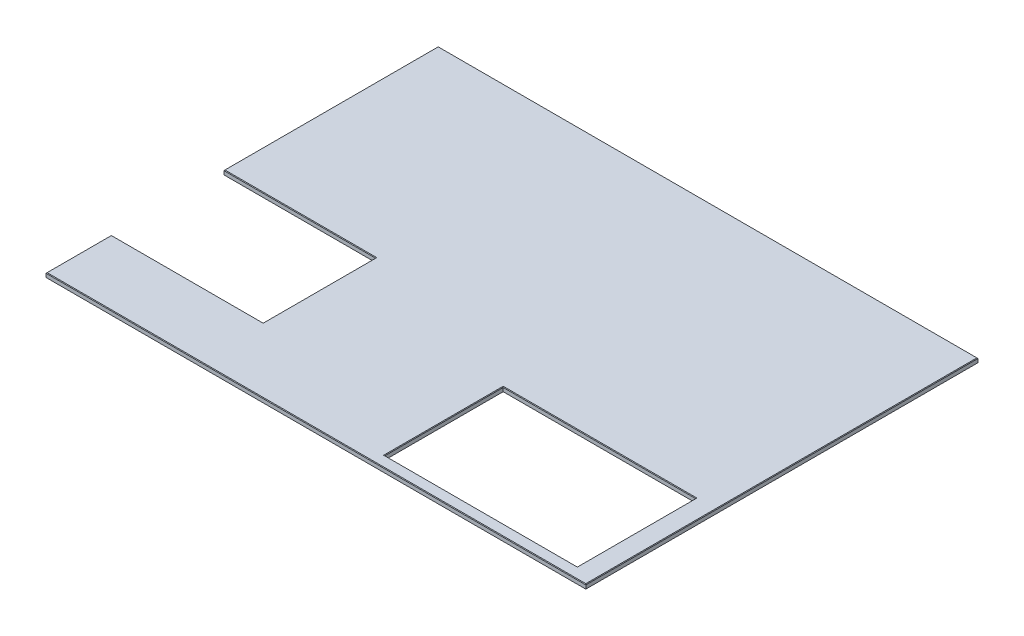
from build123d import *

# Parameters (mm, degrees)
SKETCH1_W           = 869.95
SKETCH1_H           = 534.924
BOSS_EXTRUDE1_DEPTH = 19.05
CHAMFER1_SIZE       = 2.54


with BuildPart() as part:
    # Sketch1 → Boss-Extrude1 (new body)
    with BuildSketch(Plane(origin=(0, 0, 0), x_dir=(1, 0, 0), z_dir=(0, 1, 0))):
        Polygon((2438.4, 0), (2438.4, 1771.65), (0, 1771.65), (0, 803.275), (685.8, 803.275), (685.8, 295.275), (0, 295.275), (0, 0), align=None)
        with Locations((1914.4615, 318.262)):
            Rectangle(SKETCH1_W, SKETCH1_H, mode=Mode.SUBTRACT)
    extrude(amount=-BOSS_EXTRUDE1_DEPTH)

    # Chamfer1
    chamfer1_edges = [part.edges().sort_by_distance(p)[0] for p in [
        (0, 0, -1287.4625),
        (1219.2, 0, -1771.65),
        (2438.4, 0, -885.825),
        (1219.2, 0, 0),
        (1914.4615, 0, -585.724),
        (1479.4865, 0, -318.262),
        (1914.4615, 0, -50.8),
        (2349.4365, 0, -318.262),
        (0, 0, -147.6375),
        (342.9, 0, -295.275),
        (685.8, 0, -549.275),
        (342.9, 0, -803.275),
    ]]
    chamfer(chamfer1_edges, length=CHAMFER1_SIZE)


solid = part.part
